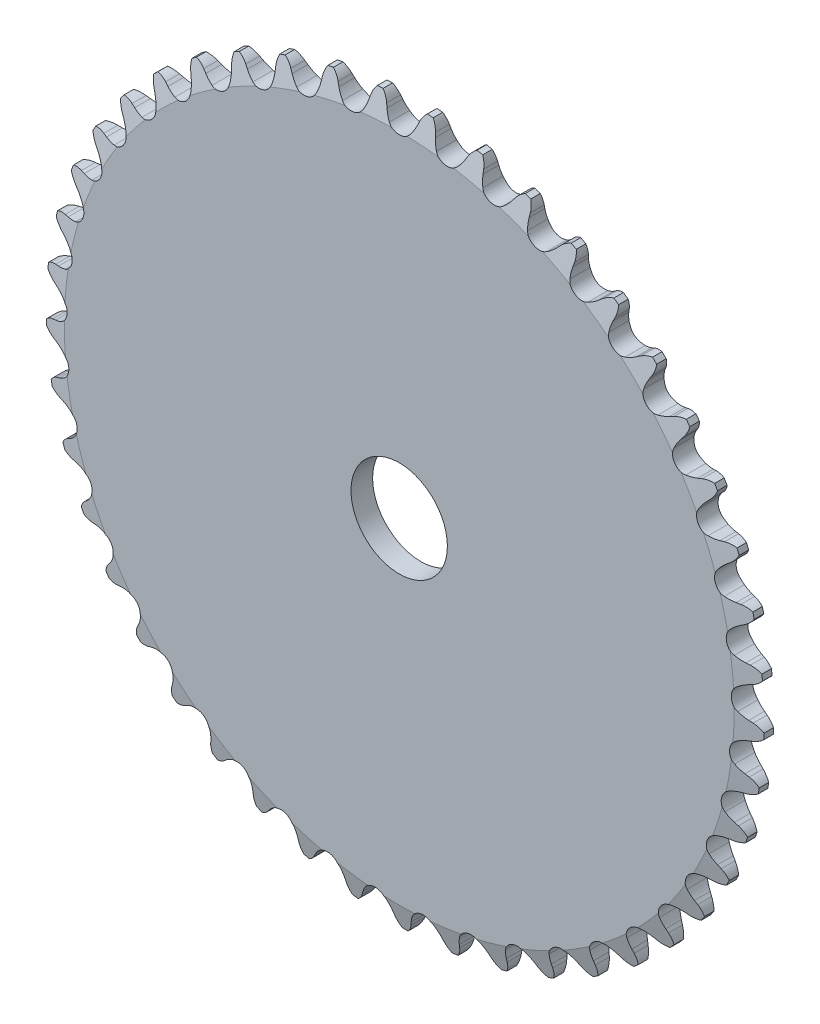
from build123d import *

# Parameters (mm, degrees)
CUT_EXTRUDE1_DEPTH      = 101.381526816
CIRPATTERN1_COUNT       = 45
CUT_EXTRUDE2_DEPTH      = 101.363515373
CUT_EXTRUDE2_DEPTH_BACK = 101.363515373
SKETCH3_OUTSIDE_W       = 184.004
SKETCH3_OUTSIDE_H       = 183.919
SKETCH3_OUTSIDE_R       = 70.993
SKETCH3_OUTSIDE_R_2     = 7.540625
CUT_EXTRUDE3_REACH      = 102.432
SKETCH5_R               = 9.525


with BuildPart() as part:
    # Sketch1 → Revolve1 (revolve)
    with BuildSketch(Plane(origin=(0, 0, 0), x_dir=(0, 0, -1), z_dir=(1, 0, 0)), mode=Mode.PRIVATE) as revolve1_sk:
        Polygon((2.1336, 0), (-2.1336, 0), (-2.1336, 66.201923048), (-0.942975, 70.964423048), (0.942975, 70.964423048), (2.1336, 66.201923048), align=None)
    revolve(revolve1_sk.sketch.rotate(Axis((0, 0, -2.1336), (0, 0, 1)), 90), axis=Axis((0, 0, -2.1336), (0, 0, 1)))

    # Sketch0 → Cut-Extrude1 (cut, symmetric)
    with BuildSketch(Plane.XY):
        with BuildLine():
            Line((8.059102042, -68.752061704), (7.763789226, -68.075402129))
            ThreePointArc((7.763789226, -68.075402129), (7.310869953, -67.215151558), (6.73744589, -66.430070826))
            ThreePointArc((6.73744589, -66.430070826), (4.581774928, -65.522434106), (2.573401424, -66.72124918))
            ThreePointArc((2.573401424, -66.72124918), (2.114820005, -67.578494766), (1.78603225, -68.493407616))
            Line((1.78603225, -68.493407616), (1.587766209, -69.204581588))
            ThreePointArc((1.587766209, -69.204581588), (0.065884539, -71.404321568), (-2.49042048, -72.191902961))
            ThreePointArc((-2.49042048, -72.191902961), (5.038848173, -72.058886033), (12.513354879, -71.142736783))
            ThreePointArc((12.513354879, -71.142736783), (9.8723175, -70.718588975), (8.059102042, -68.752061704))
        make_face()
    cut_extrude1 = extrude(amount=CUT_EXTRUDE1_DEPTH, both=True, mode=Mode.SUBTRACT)

    # CirPattern1: Cut-Extrude1 ×45 about axis
    cirpattern1_axis = Axis((0, 0, 0), (0, 0, 1))
    for i in range(1, CIRPATTERN1_COUNT):
        add(cut_extrude1.rotate(cirpattern1_axis, i * 360 / CIRPATTERN1_COUNT), mode=Mode.SUBTRACT)

    # Sketch3 outside → Cut-Extrude2 (cut, two sides: drawn at the far end of the back side and taken through both)
    # profile 1 of 2: a face of its own
    with BuildSketch(Plane.XY.offset(-CUT_EXTRUDE2_DEPTH_BACK)):
        with Locations((0, -0.0675)):
            Rectangle(SKETCH3_OUTSIDE_W, SKETCH3_OUTSIDE_H)
        Circle(SKETCH3_OUTSIDE_R, mode=Mode.SUBTRACT)
    # profile 2 of 2: a face of its own
    with BuildSketch(Plane.XY.offset(-CUT_EXTRUDE2_DEPTH_BACK)):
        Circle(SKETCH3_OUTSIDE_R_2)
    extrude(amount=CUT_EXTRUDE2_DEPTH + CUT_EXTRUDE2_DEPTH_BACK, mode=Mode.SUBTRACT)

    # Sketch5 → Cut-Extrude3 (cut, up to next)
    with BuildSketch(Plane.XY.offset(2.1336), mode=Mode.PRIVATE) as cut_extrude3_sk1:
        Circle(SKETCH5_R)
    cut_extrude3_tool1 = extrude(cut_extrude3_sk1.sketch, amount=-CUT_EXTRUDE3_REACH, mode=Mode.PRIVATE) & part.part
    add(cut_extrude3_tool1.solids().sort_by_distance((0, 0, 2.1336))[0], mode=Mode.SUBTRACT)


solid = part.part
